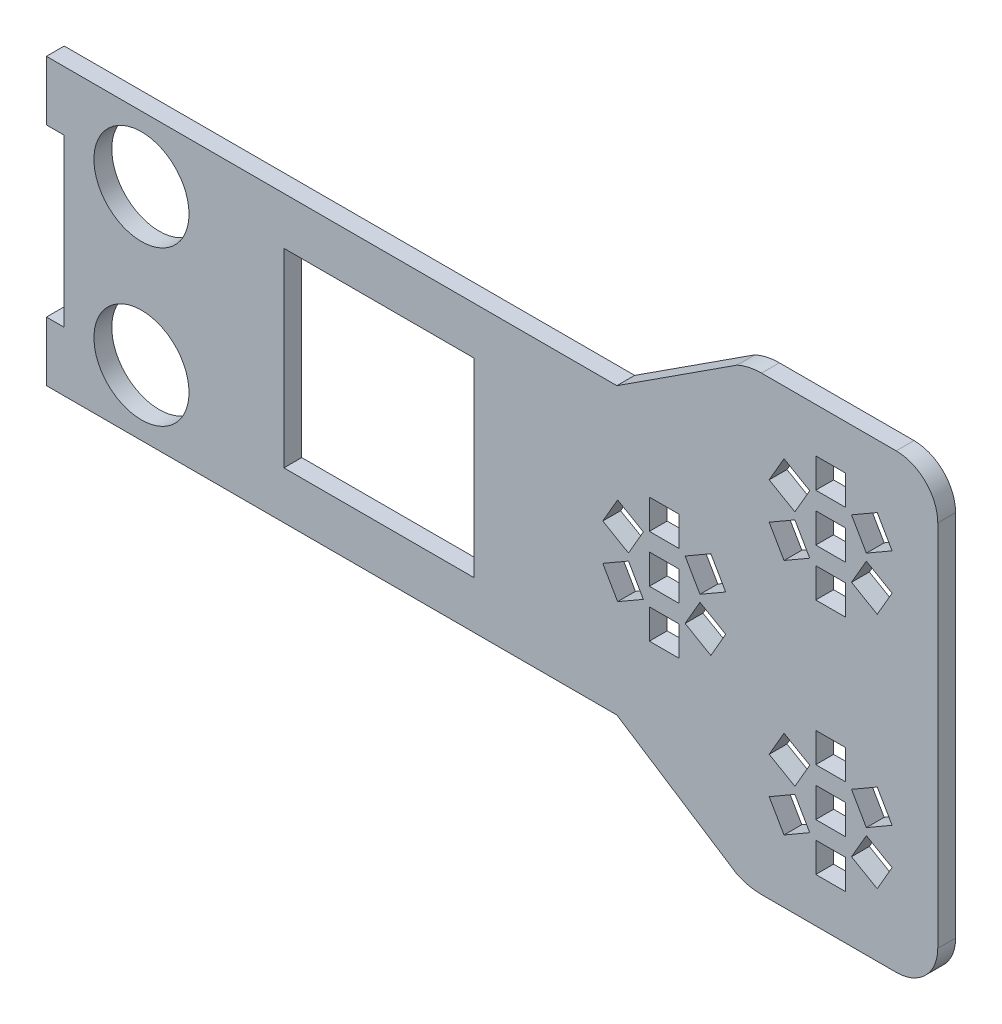
from build123d import *

# Parameters (mm, degrees)
MODEL_R                 = 8
MODEL_W                 = 32
MODEL_H                 = 32
MODEL_W_2               = 5
MODEL_H_2               = 5
SALIENTE_EXTRUIR1_DEPTH = 3


with BuildPart() as part:
    # Model → Saliente-Extruir1 (new body)
    with BuildSketch(Plane.XY):
        with BuildLine():
            Line((-57.824686592, 11.748368167), (-57.824686592, 39.748368167))
            Line((-57.824686592, 39.748368167), (-60.824686592, 39.748368167))
            Line((-60.824686592, 39.748368167), (-60.824686592, 49.748368167))
            Line((-60.824686592, 49.748368167), (35.175313408, 49.748368167))
            Line((35.175313408, 49.748368167), (55.431974906, 62.876149377))
            ThreePointArc((55.431974906, 62.876149377), (57.428209194, 63.52788278), (59.516532433, 63.748368167))
            Line((59.516532433, 63.748368167), (82.175313408, 63.748368167))
            ThreePointArc((82.175313408, 63.748368167), (87.125060876, 61.698115636), (89.175313408, 56.748368167))
            Line((89.175313408, 56.748368167), (89.175313408, -5.251631833))
            ThreePointArc((89.175313408, -5.251631833), (87.125060876, -10.201379301), (82.175313408, -12.251631833))
            Line((82.175313408, -12.251631833), (59.516532433, -12.251631833))
            ThreePointArc((59.516532433, -12.251631833), (57.428209194, -12.031146445), (55.431974906, -11.379413042))
            Line((55.431974906, -11.379413042), (35.175313408, 1.748368167))
            Line((35.175313408, 1.748368167), (-60.824686592, 1.748368167))
            Line((-60.824686592, 1.748368167), (-60.824686592, 11.748368167))
            Line((-60.824686592, 11.748368167), (-57.824686592, 11.748368167))
        make_face()
        with Locations((-44.824686592, 12.748368167)):
            Circle(MODEL_R, mode=Mode.SUBTRACT)
        with Locations((-44.824686592, 38.748368167)):
            Circle(MODEL_R, mode=Mode.SUBTRACT)
        with Locations((-4.85604759, 25.748368167)):
            Rectangle(MODEL_W, MODEL_H, mode=Mode.SUBTRACT)
        Polygon((65.130812689, 45.163431677), (67.630812689, 40.833304658), (63.300685671, 38.333304658), (60.800685671, 42.663431677), align=None, mode=Mode.SUBTRACT)
        Polygon((65.130812689, 5.163431677), (67.630812689, 0.833304658), (63.300685671, -1.666695342), (60.800685671, 2.663431677), align=None, mode=Mode.SUBTRACT)
        Polygon((37.130812689, 25.163431677), (39.630812689, 20.833304658), (35.300685671, 18.333304658), (32.800685671, 22.663431677), align=None, mode=Mode.SUBTRACT)
        Polygon((60.800685671, 48.833304658), (63.300685671, 53.163431677), (67.630812689, 50.663431677), (65.130812689, 46.333304658), align=None, mode=Mode.SUBTRACT)
        Polygon((60.800685671, 8.833304658), (63.300685671, 13.163431677), (67.630812689, 10.663431677), (65.130812689, 6.333304658), align=None, mode=Mode.SUBTRACT)
        Polygon((32.800685671, 28.833304658), (35.300685671, 33.163431677), (39.630812689, 30.663431677), (37.130812689, 26.333304658), align=None, mode=Mode.SUBTRACT)
        with Locations((71.14395241, 37.748368167)):
            Rectangle(MODEL_W_2, MODEL_H_2, mode=Mode.SUBTRACT)
        with Locations((71.14395241, -2.251631833)):
            Rectangle(MODEL_W_2, MODEL_H_2, mode=Mode.SUBTRACT)
        with Locations((43.14395241, 17.748368167)):
            Rectangle(MODEL_W_2, MODEL_H_2, mode=Mode.SUBTRACT)
        Polygon((77.157092131, 46.333304658), (74.657092131, 50.663431677), (78.98721915, 53.163431677), (81.48721915, 48.833304658), align=None, mode=Mode.SUBTRACT)
        Polygon((77.157092131, 6.333304658), (74.657092131, 10.663431677), (78.98721915, 13.163431677), (81.48721915, 8.833304658), align=None, mode=Mode.SUBTRACT)
        Polygon((49.157092131, 26.333304658), (46.657092131, 30.663431677), (50.98721915, 33.163431677), (53.48721915, 28.833304658), align=None, mode=Mode.SUBTRACT)
        Polygon((81.48721915, 42.663431677), (78.98721915, 38.333304658), (74.657092131, 40.833304658), (77.157092131, 45.163431677), align=None, mode=Mode.SUBTRACT)
        Polygon((81.48721915, 2.663431677), (78.98721915, -1.666695342), (74.657092131, 0.833304658), (77.157092131, 5.163431677), align=None, mode=Mode.SUBTRACT)
        Polygon((53.48721915, 22.663431677), (50.98721915, 18.333304658), (46.657092131, 20.833304658), (49.157092131, 25.163431677), align=None, mode=Mode.SUBTRACT)
        with Locations((71.14395241, 13.748368167)):
            Rectangle(MODEL_W_2, MODEL_H_2, mode=Mode.SUBTRACT)
        with Locations((43.14395241, 33.748368167)):
            Rectangle(MODEL_W_2, MODEL_H_2, mode=Mode.SUBTRACT)
        with Locations((71.14395241, 53.748368167)):
            Rectangle(MODEL_W_2, MODEL_H_2, mode=Mode.SUBTRACT)
        with Locations((71.14395241, 5.748368167)):
            Rectangle(MODEL_W_2, MODEL_H_2, mode=Mode.SUBTRACT)
        with Locations((43.14395241, 25.748368167)):
            Rectangle(MODEL_W_2, MODEL_H_2, mode=Mode.SUBTRACT)
        with Locations((71.14395241, 45.748368167)):
            Rectangle(MODEL_W_2, MODEL_H_2, mode=Mode.SUBTRACT)
    extrude(amount=SALIENTE_EXTRUIR1_DEPTH)


solid = part.part
